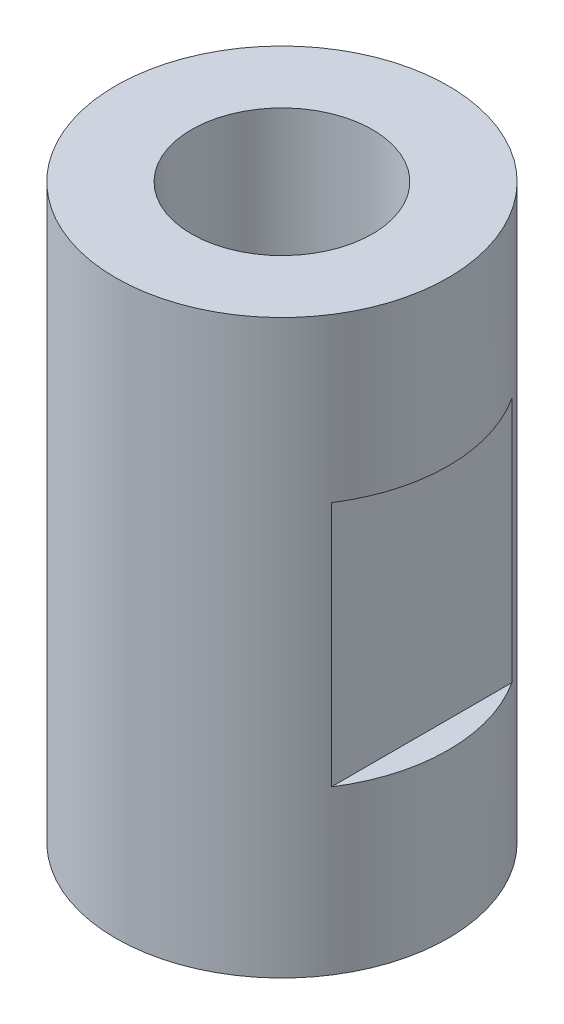
from build123d import *

# Parameters (mm, degrees)
SKETCH1_R                    = 6.35
BOSS_EXTRUDE1_DEPTH          = 21.844
SKETCH4_W                    = 4.630102794
SKETCH4_H                    = 9.398
SKETCH4_W_2                  = 5.584398789
CUT_EXTRUDE5_DEPTH           = 13.7
M5X0_8_TAPPED_HOLE2_D        = 4.2
F_5_16_24_TAPPED_HOLE1_D     = 6.9088
F_5_16_24_TAPPED_HOLE1_DEPTH = 6.35
F_5_16_24_TAPPED_HOLE1_TIP   = 2.075612922


with BuildPart() as part:
    # Sketch1 → Boss-Extrude1 (new body)
    with BuildSketch(Plane(origin=(0, 0, 0), x_dir=(1, 0, 0), z_dir=(0, 1, 0))):
        Circle(SKETCH1_R)
    extrude(amount=-BOSS_EXTRUDE1_DEPTH)

    # Sketch4 → Cut-Extrude5 (cut, through all)
    with BuildSketch(Plane(origin=(0, 0, -6.35), x_dir=(-1, 0, 0), z_dir=(0, 0, -1))):
        with Locations((-7.649051397, -10.922)):
            Rectangle(SKETCH4_W, SKETCH4_H)
        with Locations((8.126199395, -10.922)):
            Rectangle(SKETCH4_W_2, SKETCH4_H)
    extrude(amount=-CUT_EXTRUDE5_DEPTH, mode=Mode.SUBTRACT)

    # M5x0.8 Tapped Hole2 (through all)
    with Locations(Plane(origin=(0, 0, 0), x_dir=(1, 0, 0), z_dir=(0, 1, 0))):
        with Locations((0, 0)):
            Hole(M5X0_8_TAPPED_HOLE2_D / 2)

    # 5/16-24 Tapped Hole1
    with Locations(Plane(origin=(0, 0, 0), x_dir=(1, 0, 0), z_dir=(0, 1, 0))):
        with Locations((0, 0)):
            Hole(F_5_16_24_TAPPED_HOLE1_D / 2, depth=F_5_16_24_TAPPED_HOLE1_DEPTH)
            with Locations((0, 0, -(F_5_16_24_TAPPED_HOLE1_DEPTH + F_5_16_24_TAPPED_HOLE1_TIP / 2))):  # 118° drill point
                Cone(0, F_5_16_24_TAPPED_HOLE1_D / 2, F_5_16_24_TAPPED_HOLE1_TIP, mode=Mode.SUBTRACT)


solid = part.part
